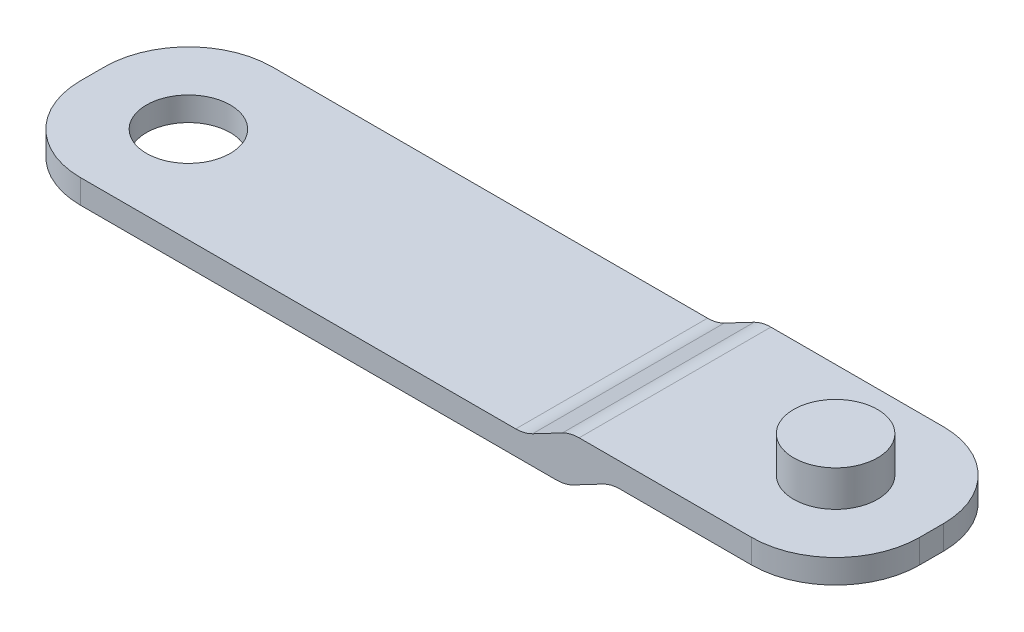
from build123d import *

# Parameters (mm, degrees)
BOSS_EXTRUDE1_DEPTH = 4
SKETCH4_W           = 7
SKETCH4_H           = 2
CUT_EXTRUDE2_DEPTH  = 17.000717669
FILLET1_R           = 3
SKETCH5_R           = 3.5
BOSS_EXTRUDE2_DEPTH = 3


with BuildPart() as part:
    # Sketch1 → Boss-Extrude1 (new body)
    with BuildSketch(Plane(origin=(0, 0, 0), x_dir=(1, 0, 0), z_dir=(0, 1, 0))):
        with BuildLine():
            Line((35.408940815, -1.068857927), (35.408963598, 0.931142073))
            ThreePointArc((35.408963598, 0.931142073), (33.358767452, 5.880912897), (28.40904334, 7.931221814))
            Line((28.40904334, 7.931221814), (-12.665132622, 7.931689714))
            Line((-12.665132622, 7.931689714), (-27.590956657, 7.931859742))
            ThreePointArc((-27.590956657, 7.931859742), (-32.54072748, 5.881663596), (-34.591036397, 0.931939484))
            Line((-34.591036397, 0.931939484), (-34.591059181, -1.068060516))
            ThreePointArc((-34.591059181, -1.068060516), (-32.540863035, -6.01783134), (-27.591138922, -8.068140257))
            Line((-27.591138922, -8.068140257), (-12.665314887, -8.068310285))
            Line((-12.665314887, -8.068310285), (28.408861074, -8.068778185))
            ThreePointArc((28.408861074, -8.068778185), (33.358631898, -6.018582039), (35.408940815, -1.068857927))
        make_face()
        with BuildLine():
            ThreePointArc((27.408912336, -3.568766794), (30.908952207, -0.068806665), (27.408992077, 3.431233206))
            ThreePointArc((27.408992077, 3.431233206), (23.908952207, -0.068726924), (27.408912336, -3.568766794))
        make_face(mode=Mode.SUBTRACT)
        with BuildLine():
            ThreePointArc((-23.09104779, -0.068191519), (-26.591007919, 3.431848351), (-30.091047789, -0.068111778))
            ThreePointArc((-30.091047789, -0.068111778), (-26.59108766, -3.568151649), (-23.09104779, -0.068191519))
        make_face(mode=Mode.SUBTRACT)
        with BuildLine():
            ThreePointArc((27.408992077, 3.431233206), (23.908952207, -0.068726924), (27.408912336, -3.568766794))
            ThreePointArc((27.408912336, -3.568766794), (30.908952207, -0.068806665), (27.408992077, 3.431233206))
        make_face()
    extrude(amount=BOSS_EXTRUDE1_DEPTH)

    # Sketch4 → Cut-Extrude2 (cut, through all)
    with BuildSketch(Plane(origin=(-9.1912e-05, 0, 8.068454562), x_dir=(1, 0, 1.1392e-05), z_dir=(-1.1392e-05, 0, 1))):
        Polygon((9.464868883, 2), (13.271442145, 4), (-27.591047011, 4), (-27.591047011, 2), align=None)
        with Locations((-31.091047011, 3)):
            Rectangle(SKETCH4_W, SKETCH4_H)
        Polygon((28.408952989, 0), (28.408952989, 2), (16.665047436, 2), (12.858474174, 0), align=None)
        with Locations((31.908952989, 1)):
            Rectangle(SKETCH4_W, SKETCH4_H)
    extrude(amount=-CUT_EXTRUDE2_DEPTH, mode=Mode.SUBTRACT)

    # Fillet1
    fillet1_edges = [part.edges().sort_by_distance(p)[0] for p in [
        (12.858473393, 0, 0.068601041),
        (13.271441364, 4, 0.068605746),
        (16.665046655, 2, 0.068644404),
        (9.464868102, 2, 0.068562383),
    ]]
    fillet(fillet1_edges, radius=FILLET1_R)

    # Sketch5 → Boss-Extrude2 (add)
    with BuildSketch(Plane(origin=(0, 4, 0), x_dir=(1, 0, 0), z_dir=(0, 1, 0))):
        with Locations((27.408952207, -0.068766794)):
            Circle(SKETCH5_R)
    extrude(amount=BOSS_EXTRUDE2_DEPTH)


solid = part.part
